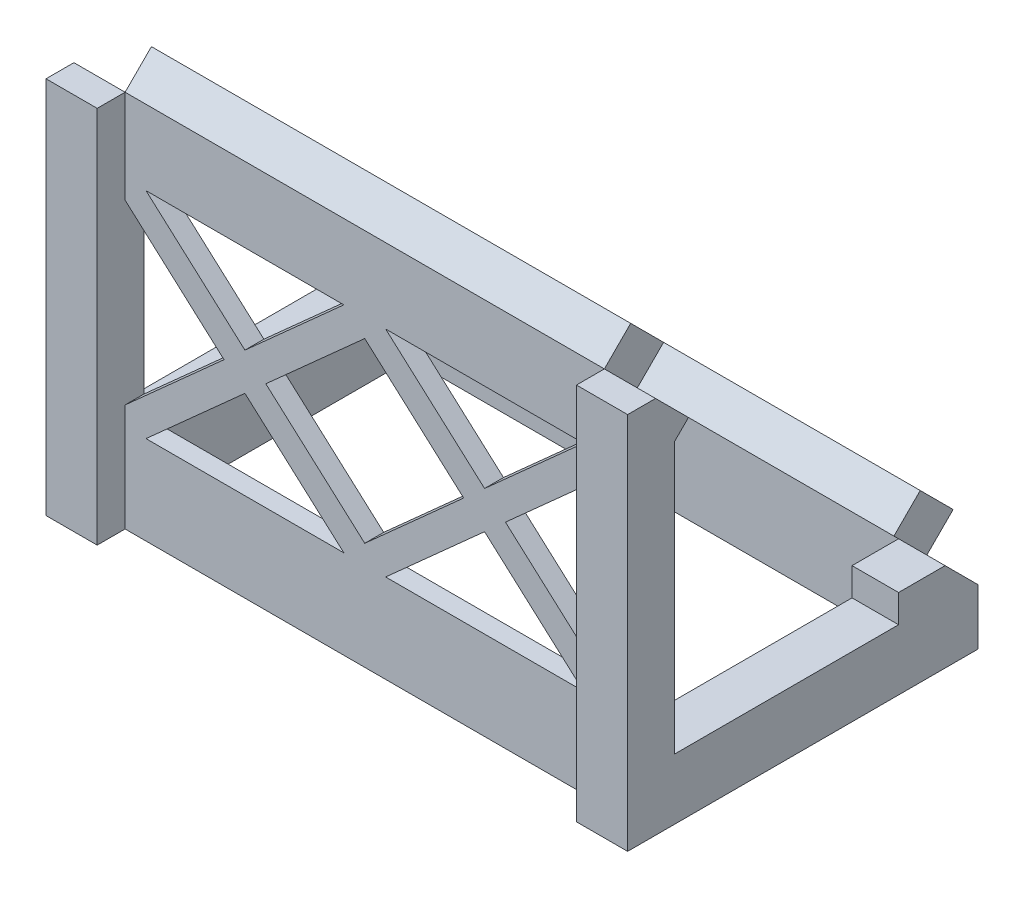
from build123d import *

# Parameters (mm, degrees)
BOSS_EXTRUDE3_DEPTH  = 125
SKETCH3_W            = 125
SKETCH3_H            = 69.296464556
BOSS_EXTRUDE5_DEPTH  = 12
CUT_EXTRUDE1_DEPTH   = 159.836393815
SKETCH7_W            = 105
SKETCH7_H            = 10
BOSS_EXTRUDE6_DEPTH  = 8
SKETCH8_W            = 105
SKETCH8_H            = 10
BOSS_EXTRUDE7_DEPTH  = 8
SKETCH9_W            = 105
SKETCH9_H            = 55.154328932
CUT_EXTRUDE2_DEPTH   = 161.78246173
SKETCH11_W           = 10
SKETCH11_H           = 55.154328932
CUT_EXTRUDE3_DEPTH   = 6
SKETCH12_W           = 10
SKETCH12_H           = 55.154328932
CUT_EXTRUDE4_DEPTH   = 6
SKETCH13_W           = 105
SKETCH13_H           = 61.154328932
CUT_EXTRUDE6_DEPTH   = 3
SKETCH14_R           = 1.9
CUT_EXTRUDE8_DEPTH   = 6
SKETCH15_R           = 1.9
CUT_EXTRUDE9_DEPTH   = 6
BOSS_EXTRUDE9_REACH  = 158.4
SKETCH25_W           = 10
SKETCH25_H           = 6
BOSS_EXTRUDE13_DEPTH = 10
CUT_EXTRUDE10_DEPTH  = 1
CUT_EXTRUDE11_DEPTH  = 1
SKETCH29_W           = 11
SKETCH29_H           = 81.296464556
BOSS_EXTRUDE15_DEPTH = 6
SKETCH31_R           = 2
CUT_EXTRUDE16_DEPTH  = 6
SKETCH32_R           = 2
CUT_EXTRUDE17_DEPTH  = 6
CUT_EXTRUDE22_DEPTH  = 157.400127877
CUT_EXTRUDE23_DEPTH  = 157.400127877
CUT_EXTRUDE26_REACH  = 164.072


with BuildPart() as part:
    # Sketch1 → Boss-Extrude3 (new body)
    with BuildSketch(Plane(origin=(0, 0, 0), x_dir=(0, 0, -1), z_dir=(1, 0, 0))):
        Polygon((0, 0), (69.296464556, 0), (0, 69.296464556), align=None)
    extrude(amount=-BOSS_EXTRUDE3_DEPTH)

    # Sketch3 → Boss-Extrude5 (add)
    with BuildSketch(Plane.XZ):
        with Locations((-62.5, -34.648232278)):
            Rectangle(SKETCH3_W, SKETCH3_H)
    extrude(amount=BOSS_EXTRUDE5_DEPTH)

    # Sketch6 → Cut-Extrude1 (cut, through all)
    with BuildSketch(Plane.ZY.offset(125)):
        Polygon((-7.071067812, 62.225396744), (-62.225396744, 7.071067812), (-7.071067812, 7.071067812), align=None)
    extrude(amount=-CUT_EXTRUDE1_DEPTH, mode=Mode.SUBTRACT)

    # Sketch7 → Boss-Extrude6 (add)
    with BuildSketch(Plane(origin=(0, 34.648232278, -34.648232278), x_dir=(1, 0, 0), z_dir=(0, 0.7071067811865515, -0.7071067811865436))):
        with Locations((-62.5, 44)):
            Rectangle(SKETCH7_W, SKETCH7_H)
    extrude(amount=BOSS_EXTRUDE6_DEPTH)

    # Sketch8 → Boss-Extrude7 (add)
    with BuildSketch(Plane(origin=(0, 34.648232278, -34.648232278), x_dir=(1, 0, 0), z_dir=(0, 0.7071067811865515, -0.7071067811865436))):
        with Locations((-62.5, -44)):
            Rectangle(SKETCH8_W, SKETCH8_H)
    extrude(amount=BOSS_EXTRUDE7_DEPTH)

    # Sketch9 → Cut-Extrude2 (cut, through all)
    with BuildSketch(Plane(origin=(0, 7.071067812, 0), x_dir=(1, 0, 0), z_dir=(0, 1, 0))):
        with Locations((-62.5, 34.648232278)):
            Rectangle(SKETCH9_W, SKETCH9_H)
    extrude(amount=-CUT_EXTRUDE2_DEPTH, mode=Mode.SUBTRACT)

    # Sketch11 → Cut-Extrude3 (cut)
    with BuildSketch(Plane(origin=(0, 7.071067812, 0), x_dir=(1, 0, 0), z_dir=(0, 1, 0))):
        with Locations((-5, 34.648232278)):
            Rectangle(SKETCH11_W, SKETCH11_H)
    extrude(amount=-CUT_EXTRUDE3_DEPTH, mode=Mode.SUBTRACT)

    # Sketch12 → Cut-Extrude4 (cut)
    with BuildSketch(Plane(origin=(0, 7.071067812, 0), x_dir=(1, 0, 0), z_dir=(0, 1, 0))):
        with Locations((-120, 34.648232278)):
            Rectangle(SKETCH12_W, SKETCH12_H)
    extrude(amount=-CUT_EXTRUDE4_DEPTH, mode=Mode.SUBTRACT)

    # Sketch13 → Cut-Extrude6 (cut)
    with BuildSketch(Plane(origin=(0, 0, -7.071067812), x_dir=(-1, 0, 0), z_dir=(0, 0, -1))):
        with Locations((62.5, 31.648232278)):
            Rectangle(SKETCH13_W, SKETCH13_H)
    extrude(amount=-CUT_EXTRUDE6_DEPTH, mode=Mode.SUBTRACT)

    # Sketch14 → Cut-Extrude8 (cut)
    with BuildSketch(Plane(origin=(0, 34.648232278, -34.648232278), x_dir=(1, 0, 0), z_dir=(0, 0.7071067811865515, -0.7071067811865436))):
        with Locations(Location((-6.25, 42.75, 0), (0, 0, 270))):
            Circle(SKETCH14_R)
    cut_extrude8 = extrude(amount=-CUT_EXTRUDE8_DEPTH, mode=Mode.SUBTRACT)

    # Mirror1: Cut-Extrude8 across plane
    add(cut_extrude8.mirror(Plane(origin=(-62.5, 0, 0), x_dir=(0, 0, 1), z_dir=(1, 0, 0))), mode=Mode.SUBTRACT)

    # Sketch15 → Cut-Extrude9 (cut)
    with BuildSketch(Plane(origin=(0, 34.648232278, -34.648232278), x_dir=(1, 0, 0), z_dir=(0, 0.7071067811865515, -0.7071067811865436))):
        with Locations(Location((-6.25, -42.75, 0), (0, 0, 270))):
            Circle(SKETCH15_R)
    cut_extrude9 = extrude(amount=-CUT_EXTRUDE9_DEPTH, mode=Mode.SUBTRACT)

    # Mirror2: Cut-Extrude9 across plane
    add(cut_extrude9.mirror(Plane(origin=(-62.5, 0, 0), x_dir=(0, 0, 1), z_dir=(1, 0, 0))), mode=Mode.SUBTRACT)

    # Sketch22 → Boss-Extrude9 (add, up to next)
    with BuildSketch(Plane.ZY.offset(10), mode=Mode.PRIVATE) as boss_extrude9_sk1:
        Polygon((-7.071067812, 62.225396744), (-4.071067812, 59.225396744), (-4.071067812, 62.225396744), align=None)
    boss_extrude9_tool1 = extrude(boss_extrude9_sk1.sketch, amount=BOSS_EXTRUDE9_REACH, mode=Mode.PRIVATE) - part.part
    add(boss_extrude9_tool1.solids().sort_by_distance((-10, 61.225397, -5.071068))[0])

    # Sketch25 → Boss-Extrude13 (add)
    with BuildSketch(Plane.XY.offset(-62.225396744)):
        with Locations((-5, 4.071067812)):
            Rectangle(SKETCH25_W, SKETCH25_H)
        with Locations((-120, 4.071067812)):
            Rectangle(SKETCH25_W, SKETCH25_H)
    extrude(amount=BOSS_EXTRUDE13_DEPTH)

    # Sketch26 → Cut-Extrude10 (cut)
    with BuildSketch(Plane(origin=(-10, 0, 0), x_dir=(0, 0, -1), z_dir=(1, 0, 0))):
        Polygon((0, 69.296464556), (7.071067812, 62.225396744), (12.727922061, 67.882250994), (5.656854249, 74.953318806), align=None)
    cut_extrude10 = extrude(amount=-CUT_EXTRUDE10_DEPTH, mode=Mode.SUBTRACT)

    # Sketch27 → Cut-Extrude11 (cut)
    with BuildSketch(Plane(origin=(-10, 0, 0), x_dir=(0, 0, -1), z_dir=(1, 0, 0))):
        Polygon((62.225396744, 7.071067812), (69.296464556, 0), (74.953318806, 5.656854249), (67.882250994, 12.727922061), align=None)
    cut_extrude11 = extrude(amount=-CUT_EXTRUDE11_DEPTH, mode=Mode.SUBTRACT)

    # Mirror3: Cut-Extrude10, Cut-Extrude11 across plane
    add(cut_extrude10.mirror(Plane(origin=(-62.5, 0, 0), x_dir=(0, 0, 1), z_dir=(1, 0, 0))), mode=Mode.SUBTRACT)
    add(cut_extrude11.mirror(Plane(origin=(-62.5, 0, 0), x_dir=(0, 0, 1), z_dir=(1, 0, 0))), mode=Mode.SUBTRACT)

    # Sketch29 → Boss-Extrude15 (add)
    with BuildSketch(Plane.XY):
        with Locations((-5.5, 28.648232278)):
            Rectangle(SKETCH29_W, SKETCH29_H)
    boss_extrude15 = extrude(amount=BOSS_EXTRUDE15_DEPTH)

    # Mirror4: Boss-Extrude15 across plane
    add(boss_extrude15.mirror(Plane(origin=(-62.5, 0, 0), x_dir=(0, 0, 1), z_dir=(1, 0, 0))))

    # Sketch31 → Cut-Extrude16 (cut)
    with BuildSketch(Plane(origin=(0, 34.648232278, -34.648232278), x_dir=(1, 0, 0), z_dir=(0, 0.7071067811865513, -0.7071067811865438))):
        with Locations(Location((-6.25, 42.75, 0), (0, 0, 270))):
            Circle(SKETCH31_R)
    cut_extrude16 = extrude(amount=-CUT_EXTRUDE16_DEPTH, mode=Mode.SUBTRACT)

    # Sketch32 → Cut-Extrude17 (cut)
    with BuildSketch(Plane(origin=(0, 34.648232278, -34.648232278), x_dir=(1, 0, 0), z_dir=(0, 0.7071067811865513, -0.7071067811865438))):
        with Locations(Location((-6.25, -42.75, 0), (0, 0, 270))):
            Circle(SKETCH32_R)
    cut_extrude17 = extrude(amount=-CUT_EXTRUDE17_DEPTH, mode=Mode.SUBTRACT)

    # Mirror5: Cut-Extrude16, Cut-Extrude17 across plane
    add(cut_extrude16.mirror(Plane(origin=(-62.5, 0, 0), x_dir=(0, 0, 1), z_dir=(1, 0, 0))), mode=Mode.SUBTRACT)
    add(cut_extrude17.mirror(Plane(origin=(-62.5, 0, 0), x_dir=(0, 0, 1), z_dir=(1, 0, 0))), mode=Mode.SUBTRACT)

    # Sketch41 → Cut-Extrude22 (cut, through all)
    with BuildSketch(Plane.ZY.offset(10)):
        Polygon((-7.071067812, 1.071067812), (-4.071067812, 1.071067812), (-4.071067812, 59.225396744), (-7.071067812, 62.225396744), align=None)
    extrude(amount=-CUT_EXTRUDE22_DEPTH, mode=Mode.SUBTRACT)

    # Sketch42 → Cut-Extrude23 (cut, through all)
    with BuildSketch(Plane(origin=(-115, 0, 0), x_dir=(0, 0, -1), z_dir=(1, 0, 0))):
        Polygon((7.071067812, 1.071067812), (4.071067812, 1.071067812), (4.071067812, 59.225396744), (7.071067812, 62.225396744), align=None)
    extrude(amount=-CUT_EXTRUDE23_DEPTH, mode=Mode.SUBTRACT)

    # Sketch43 → Cut-Extrude26 (cut, up to next)
    with BuildSketch(Plane(origin=(0, 0, -4.071067812), x_dir=(-1, 0, 0), z_dir=(0, 0, -1)), mode=Mode.PRIVATE) as cut_extrude26_sk1:
        Polygon((36.748988877, 34.169774937), (58.011664466, 53.225396744), (15.486313289, 53.225396744), align=None)
    cut_extrude26_tool1 = extrude(cut_extrude26_sk1.sketch, amount=-CUT_EXTRUDE26_REACH, mode=Mode.PRIVATE) & part.part
    # Sketch43 → Cut-Extrude26 (cut, up to next)
    with BuildSketch(Plane(origin=(0, 0, -4.071067812), x_dir=(-1, 0, 0), z_dir=(0, 0, -1)), mode=Mode.PRIVATE) as cut_extrude26_sk2:
        Polygon((32.260614543, 30.147291337), (11, 49.201066035), (11, 11.093516639), align=None)
    cut_extrude26_tool2 = extrude(cut_extrude26_sk2.sketch, amount=-CUT_EXTRUDE26_REACH, mode=Mode.PRIVATE) & part.part
    # Sketch43 → Cut-Extrude26 (cut, up to next)
    with BuildSketch(Plane(origin=(0, 0, -4.071067812), x_dir=(-1, 0, 0), z_dir=(0, 0, -1)), mode=Mode.PRIVATE) as cut_extrude26_sk3:
        Polygon((58.009015214, 7.07156019), (36.747854103, 26.125824723), (15.486143585, 7.071067812), (58.008465808, 7.071067812), align=None)
    cut_extrude26_tool3 = extrude(cut_extrude26_sk3.sketch, amount=-CUT_EXTRUDE26_REACH, mode=Mode.PRIVATE) & part.part
    # Sketch43 → Cut-Extrude26 (cut, up to next)
    with BuildSketch(Plane(origin=(0, 0, -4.071067812), x_dir=(-1, 0, 0), z_dir=(0, 0, -1)), mode=Mode.PRIVATE) as cut_extrude26_sk4:
        Polygon((83.760065137, 30.149665598), (62.498904026, 49.20393013), (41.236228437, 30.148308322), (62.497389548, 11.09404379), align=None)
    cut_extrude26_tool4 = extrude(cut_extrude26_sk4.sketch, amount=-CUT_EXTRUDE26_REACH, mode=Mode.PRIVATE) & part.part
    # Sketch43 → Cut-Extrude26 (cut, up to next)
    with BuildSketch(Plane(origin=(0, 0, -4.071067812), x_dir=(-1, 0, 0), z_dir=(0, 0, -1)), mode=Mode.PRIVATE) as cut_extrude26_sk5:
        Polygon((109.511664466, 7.071067812), (88.249757212, 26.126001038), (66.987849957, 7.071067812), align=None)
    cut_extrude26_tool5 = extrude(cut_extrude26_sk5.sketch, amount=-CUT_EXTRUDE26_REACH, mode=Mode.PRIVATE) & part.part
    # Sketch43 → Cut-Extrude26 (cut, up to next)
    with BuildSketch(Plane(origin=(0, 0, -4.071067812), x_dir=(-1, 0, 0), z_dir=(0, 0, -1)), mode=Mode.PRIVATE) as cut_extrude26_sk6:
        Polygon((114, 11.093516639), (114, 49.203383091), (92.738092746, 30.148449865), align=None)
    cut_extrude26_tool6 = extrude(cut_extrude26_sk6.sketch, amount=-CUT_EXTRUDE26_REACH, mode=Mode.PRIVATE) & part.part
    # Sketch43 → Cut-Extrude26 (cut, up to next)
    with BuildSketch(Plane(origin=(0, 0, -4.071067812), x_dir=(-1, 0, 0), z_dir=(0, 0, -1)), mode=Mode.PRIVATE) as cut_extrude26_sk7:
        Polygon((109.508465808, 53.225396744), (66.988335534, 53.225396744), (88.248400671, 34.172114425), align=None)
    cut_extrude26_tool7 = extrude(cut_extrude26_sk7.sketch, amount=-CUT_EXTRUDE26_REACH, mode=Mode.PRIVATE) & part.part
    add(cut_extrude26_tool1.solids().sort_by_distance((-36.748989, 46.873523, -4.071068))[0], mode=Mode.SUBTRACT)
    add(cut_extrude26_tool2.solids().sort_by_distance((-18.086872, 30.147291, -4.071068))[0], mode=Mode.SUBTRACT)
    add(cut_extrude26_tool3.solids().sort_by_distance((-36.747854, 13.422653, -4.071068))[0], mode=Mode.SUBTRACT)
    add(cut_extrude26_tool4.solids().sort_by_distance((-62.498147, 30.148987, -4.071068))[0], mode=Mode.SUBTRACT)
    add(cut_extrude26_tool5.solids().sort_by_distance((-88.249757, 13.422712, -4.071068))[0], mode=Mode.SUBTRACT)
    add(cut_extrude26_tool6.solids().sort_by_distance((-106.912698, 30.14845, -4.071068))[0], mode=Mode.SUBTRACT)
    add(cut_extrude26_tool7.solids().sort_by_distance((-88.248401, 46.874303, -4.071068))[0], mode=Mode.SUBTRACT)


solid = part.part
